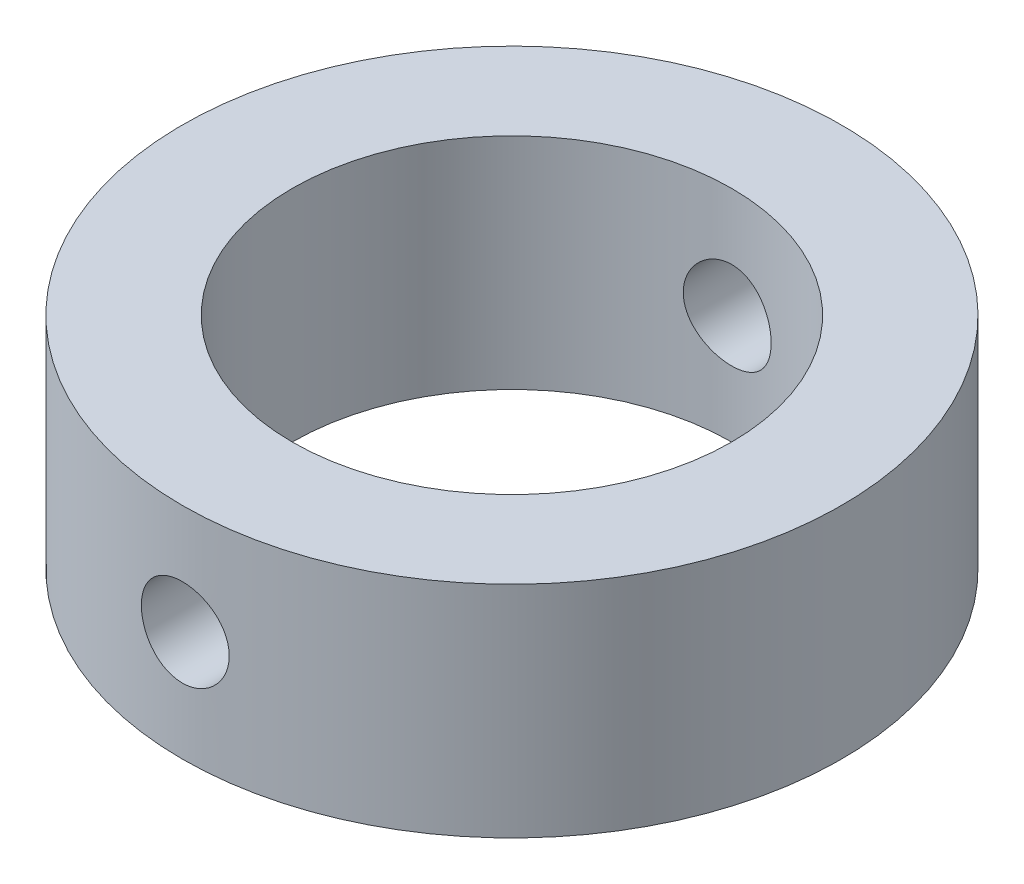
from build123d import *

# Parameters (mm, degrees)
SKETCH1_R           = 22.5
SKETCH1_R_2         = 15
BOSS_EXTRUDE1_DEPTH = 15
SKETCH2_R           = 3
CUT_EXTRUDE1_DEPTH  = 36


with BuildPart() as part:
    # Sketch1 → Boss-Extrude1 (new body)
    with BuildSketch(Plane(origin=(0, 0, 0), x_dir=(1, 0, 0), z_dir=(0, 1, 0))):
        Circle(SKETCH1_R)
        Circle(SKETCH1_R_2, mode=Mode.SUBTRACT)
    extrude(amount=BOSS_EXTRUDE1_DEPTH)

    # Sketch2 → Cut-Extrude1 (cut, symmetric)
    with BuildSketch(Plane.XY):
        with Locations((0, 7.5)):
            Circle(SKETCH2_R)
    extrude(amount=CUT_EXTRUDE1_DEPTH, both=True, mode=Mode.SUBTRACT)


solid = part.part
